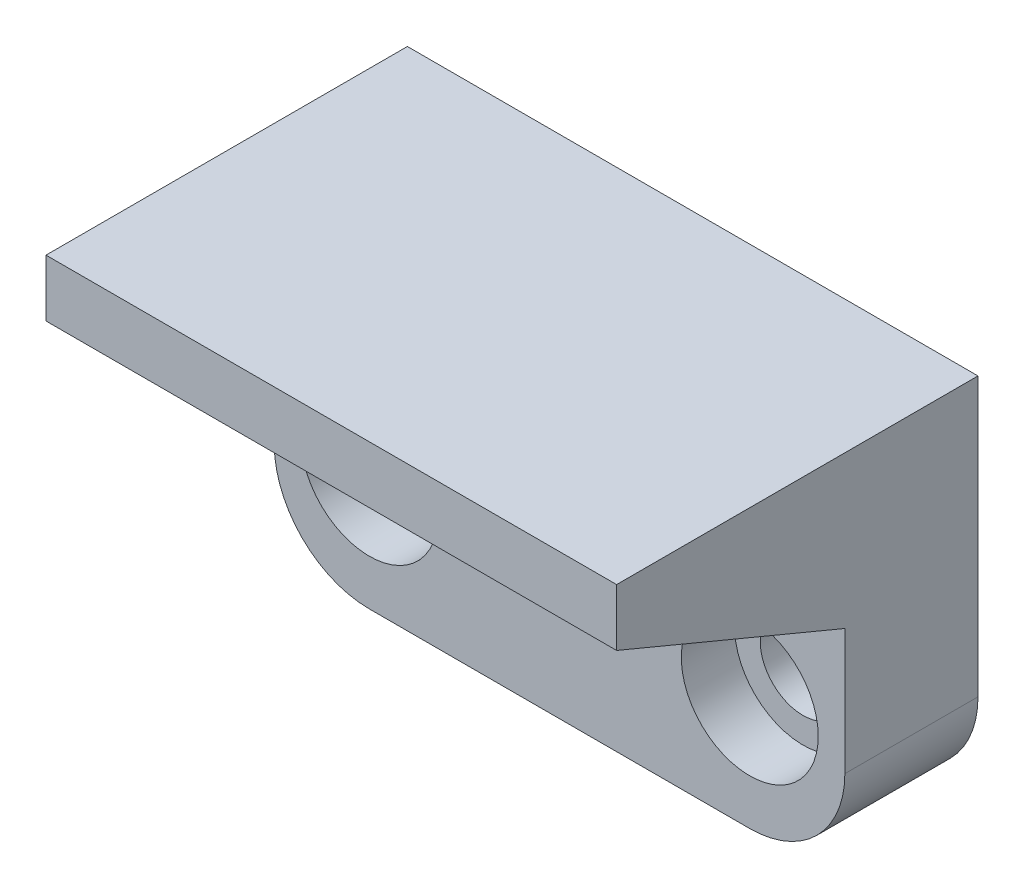
from build123d import *

# Parameters (mm, degrees)
SKETCH1_W           = 30
SKETCH1_H           = 19.61
SKETCH1_R           = 2.25
BOSS_EXTRUDE1_DEPTH = 7
SKETCH2_R           = 3.6
CUT_EXTRUDE1_DEPTH  = 2.8
FILLET2_R           = 5
BOSS_EXTRUDE2_DEPTH = 30


with BuildPart() as part:
    # Sketch1 → Boss-Extrude1 (new body)
    with BuildSketch(Plane.XY):
        Rectangle(SKETCH1_W, SKETCH1_H)
        with Locations((-10, -3.805)):
            Circle(SKETCH1_R, mode=Mode.SUBTRACT)
        with Locations((10, -3.805)):
            Circle(SKETCH1_R, mode=Mode.SUBTRACT)
    extrude(amount=BOSS_EXTRUDE1_DEPTH)

    # Sketch2 → Cut-Extrude1 (cut)
    with BuildSketch(Plane.XY.offset(7)):
        with Locations((-10, -3.805)):
            Circle(SKETCH2_R)
        with Locations((10, -3.805)):
            Circle(SKETCH2_R)
    extrude(amount=-CUT_EXTRUDE1_DEPTH, mode=Mode.SUBTRACT)

    # Fillet2
    fillet2_edges = [part.edges().sort_by_distance(p)[0] for p in [
        (15, -9.805, 3.5),
        (-15, -9.805, 3.5),
    ]]
    fillet(fillet2_edges, radius=FILLET2_R)

    # Sketch3 → Boss-Extrude2 (add, through all)
    with BuildSketch(Plane.ZY.offset(15)):
        Polygon((7, 1.805), (7, 9.805), (19, 9.805), (19, 6.805), align=None)
    extrude(amount=-BOSS_EXTRUDE2_DEPTH)


solid = part.part
